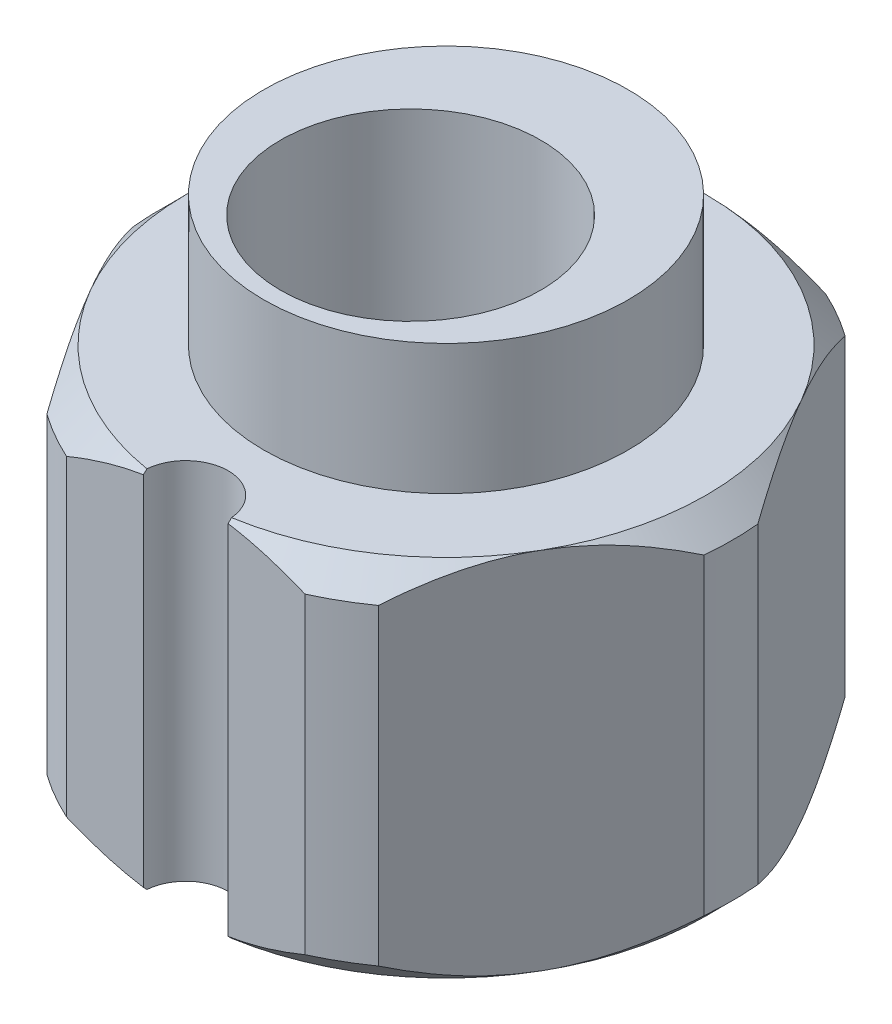
from build123d import *

# Parameters (mm, degrees)
SKETCH2_R           = 5.5
BOSS_EXTRUDE2_DEPTH = 7
CHAMFER1_SIZE       = 0.5
SKETCH3_R           = 7.5
CUT_EXTRUDE1_DEPTH  = 8
CUT_EXTRUDE2_DEPTH  = 8
SKETCH5_R           = 3.5
BOSS_EXTRUDE3_DEPTH = 2.5
SKETCH6_R           = 2.5
CUT_EXTRUDE3_DEPTH  = 10.5000001


with BuildPart() as part:
    # Sketch2 → Boss-Extrude2 (new body)
    with BuildSketch(Plane(origin=(0, 0, 0), x_dir=(1, 0, 0), z_dir=(0, 1, 0))):
        Circle(SKETCH2_R)
    extrude(amount=BOSS_EXTRUDE2_DEPTH)

    # Chamfer1
    chamfer1_edges = [part.edges().sort_by_distance(p)[0] for p in [
        (-5.5, 0, 0),
        (-5.5, 7, 0),
    ]]
    chamfer(chamfer1_edges, length=CHAMFER1_SIZE)

    # Sketch3 → Cut-Extrude1 (cut, through all)
    with BuildSketch(Plane(origin=(0, 7, 0), x_dir=(1, 0, 0), z_dir=(0, 1, 0))):
        Circle(SKETCH3_R)
        Polygon((5.773502692, 0), (2.886751346, 5), (-2.886751346, 5), (-5.773502692, 0), (-2.886751346, -5), (2.886751346, -5), align=None, mode=Mode.SUBTRACT)
    extrude(amount=-CUT_EXTRUDE1_DEPTH, mode=Mode.SUBTRACT)

    # Sketch4 → Cut-Extrude2 (cut, through all)
    with BuildSketch(Plane(origin=(0, 7, 0), x_dir=(1, 0, 0), z_dir=(0, 1, 0))):
        with BuildLine():
            Line((-0.815, -5), (0.815, -5))
            ThreePointArc((0.815, -5), (0, -4.185), (-0.815, -5))
        make_face()
    extrude(amount=-CUT_EXTRUDE2_DEPTH, mode=Mode.SUBTRACT)

    # Sketch5 → Boss-Extrude3 (add)
    with BuildSketch(Plane(origin=(0, 7, 0), x_dir=(1, 0, 0), z_dir=(0, 1, 0))):
        Circle(SKETCH5_R)
    extrude(amount=BOSS_EXTRUDE3_DEPTH)

    # Sketch6 → Cut-Extrude3 (cut, through all)
    with BuildSketch(Plane(origin=(0, 9.5, 0), x_dir=(1, 0, 0), z_dir=(0, 1, 0))):
        with Locations((0, -0.68)):
            Circle(SKETCH6_R)
    extrude(amount=-CUT_EXTRUDE3_DEPTH, mode=Mode.SUBTRACT)


solid = part.part
